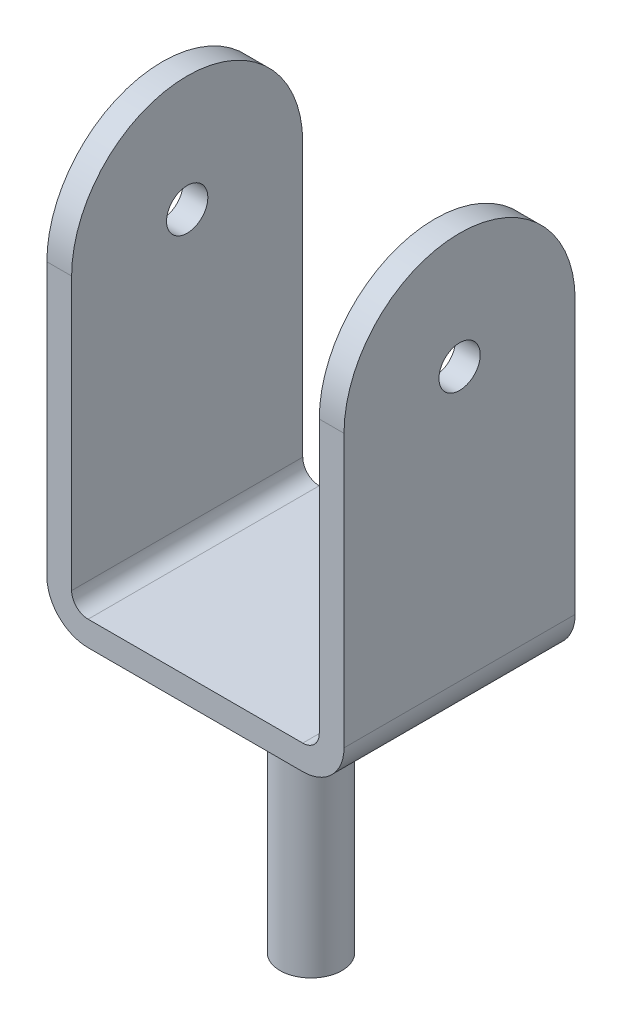
from build123d import *

# Parameters (mm, degrees)
BOSS_EXTRUDE1_DEPTH     = 280
SKETCH2_R               = 25
CUT_EXTRUDE3_DEPTH      = 1
CUT_EXTRUDE3_DEPTH_BACK = 399
SKETCH4_R               = 37.5
BOSS_EXTRUDE2_DEPTH     = 325


with BuildPart() as part:
    # Sketch1 → Boss-Extrude1 (new body)
    with BuildSketch(Plane.XY):
        with BuildLine():
            Line((-130, 0), (130, 0))
            ThreePointArc((130, 0), (165.355339059, 14.644660941), (180, 50))
            Line((180, 50), (180, 520))
            Line((180, 520), (150, 520))
            Line((150, 520), (150, 50))
            ThreePointArc((150, 50), (144.142135624, 35.857864376), (130, 30))
            Line((130, 30), (-130, 30))
            ThreePointArc((-130, 30), (-144.142135624, 35.857864376), (-150, 50))
            Line((-150, 50), (-150, 520))
            Line((-150, 520), (-180, 520))
            Line((-180, 520), (-180, 50))
            ThreePointArc((-180, 50), (-165.355339059, 14.644660941), (-130, 0))
        make_face()
    extrude(amount=BOSS_EXTRUDE1_DEPTH)

    # Sketch2 → Cut-Extrude3 (cut, two sides)
    with BuildSketch(Plane.ZY.offset(180)) as cut_extrude3_sk:
        with BuildLine():
            Line((280, 520), (140, 520))
            ThreePointArc((140, 520), (238.994949366, 478.994949366), (280, 380))
            Line((280, 380), (280, 520))
        make_face()
        with BuildLine():
            Line((0, 520), (0, 380))
            ThreePointArc((0, 380), (41.005050634, 478.994949366), (140, 520))
            Line((140, 520), (0, 520))
        make_face()
        with Locations((140, 380)):
            Circle(SKETCH2_R)
    extrude(amount=CUT_EXTRUDE3_DEPTH, mode=Mode.SUBTRACT)
    extrude(cut_extrude3_sk.sketch, amount=-CUT_EXTRUDE3_DEPTH_BACK, mode=Mode.SUBTRACT)

    # Sketch4 → Boss-Extrude2 (add)
    with BuildSketch(Plane.XZ):
        with Locations((0, 140)):
            Circle(SKETCH4_R)
    extrude(amount=BOSS_EXTRUDE2_DEPTH)


solid = part.part
